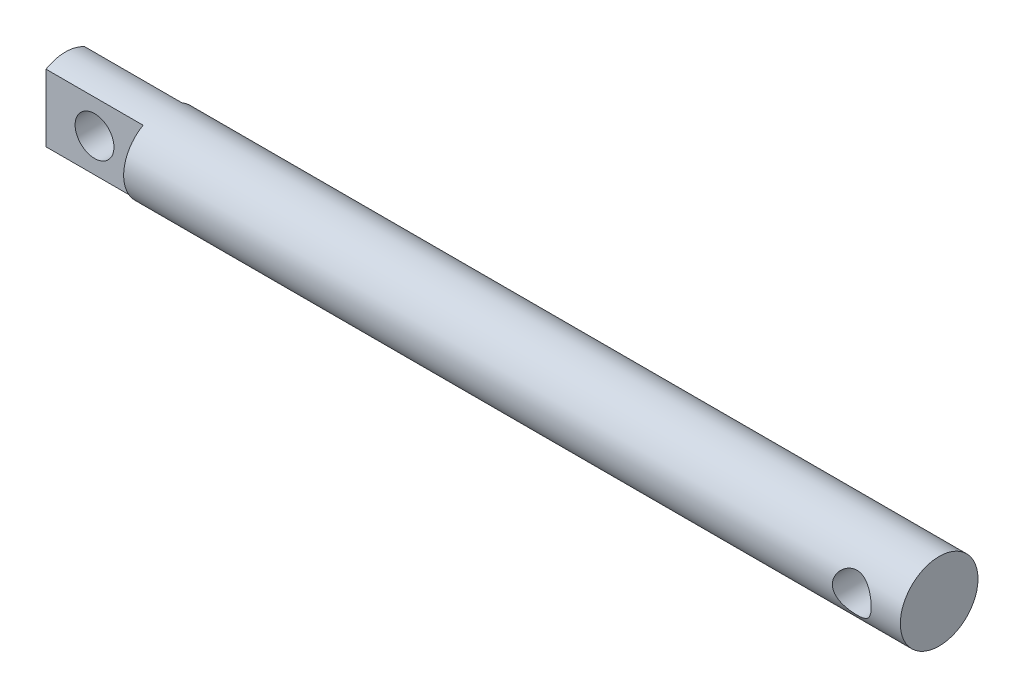
from build123d import *

# Parameters (mm, degrees)
SKETCH_1_R               = 8
EXTRUDE_1_DEPTH          = 180
SKETCH_2_R               = 4
CUT_EXTRUDE_1_DEPTH      = 9
CUT_EXTRUDE_1_DEPTH_BACK = 9
SKETCH_3_OUTSIDE_W       = 54.284
SKETCH_3_OUTSIDE_H       = 54.284
SKETCH_3_OUTSIDE_W_2     = 8
SKETCH_3_OUTSIDE_H_2     = 20
CUT_EXTRUDE_2_DEPTH      = 20


with BuildPart() as part:
    # 草图1 → 凸台-拉伸1 (new body)
    with BuildSketch(Plane(origin=(0, 0, 0), x_dir=(0, 0, -1), z_dir=(1, 0, 0))):
        Circle(SKETCH_1_R)
    extrude(amount=EXTRUDE_1_DEPTH)

    # 草图2 → 切除-拉伸1 (cut, two sides)
    with BuildSketch(Plane.XY) as cut_extrude_1_sk:
        with Locations((10, 0)):
            Circle(SKETCH_2_R)
        with Locations((170, 0)):
            Circle(SKETCH_2_R)
    extrude(amount=CUT_EXTRUDE_1_DEPTH, mode=Mode.SUBTRACT)
    extrude(cut_extrude_1_sk.sketch, amount=-CUT_EXTRUDE_1_DEPTH_BACK, mode=Mode.SUBTRACT)

    # 草图3 outside → 切除-拉伸2 (cut)
    with BuildSketch(Plane.ZY):
        Rectangle(SKETCH_3_OUTSIDE_W, SKETCH_3_OUTSIDE_H)
        Rectangle(SKETCH_3_OUTSIDE_W_2, SKETCH_3_OUTSIDE_H_2, mode=Mode.SUBTRACT)
    extrude(amount=-CUT_EXTRUDE_2_DEPTH, mode=Mode.SUBTRACT)


solid = part.part
